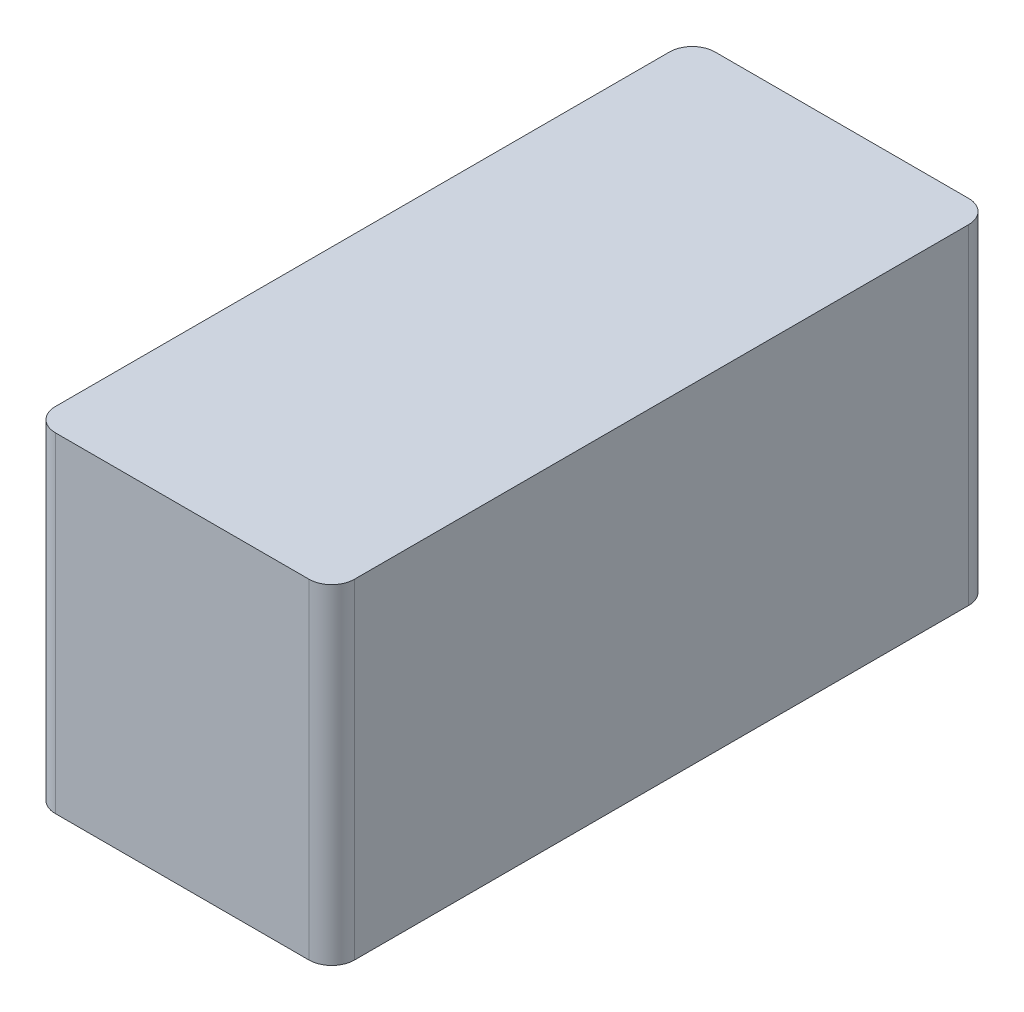
from build123d import *

# Parameters (mm, degrees)
SKETCH1_W           = 13.15
SKETCH1_H           = 29
BOSS_EXTRUDE1_DEPTH = 14.5
FILLET1_R           = 1


with BuildPart() as part:
    # Sketch1 → Boss-Extrude1 (new body)
    with BuildSketch(Plane(origin=(0, 0, 0), x_dir=(1, 0, 0), z_dir=(0, 1, 0))):
        Rectangle(SKETCH1_W, SKETCH1_H)
    extrude(amount=BOSS_EXTRUDE1_DEPTH)

    # Fillet1
    fillet1_edges = [part.edges().sort_by_distance(p)[0] for p in [
        (-6.575, 7.25, -14.5),
        (6.575, 7.25, -14.5),
        (6.575, 7.25, 14.5),
        (-6.575, 7.25, 14.5),
    ]]
    fillet(fillet1_edges, radius=FILLET1_R)


solid = part.part
